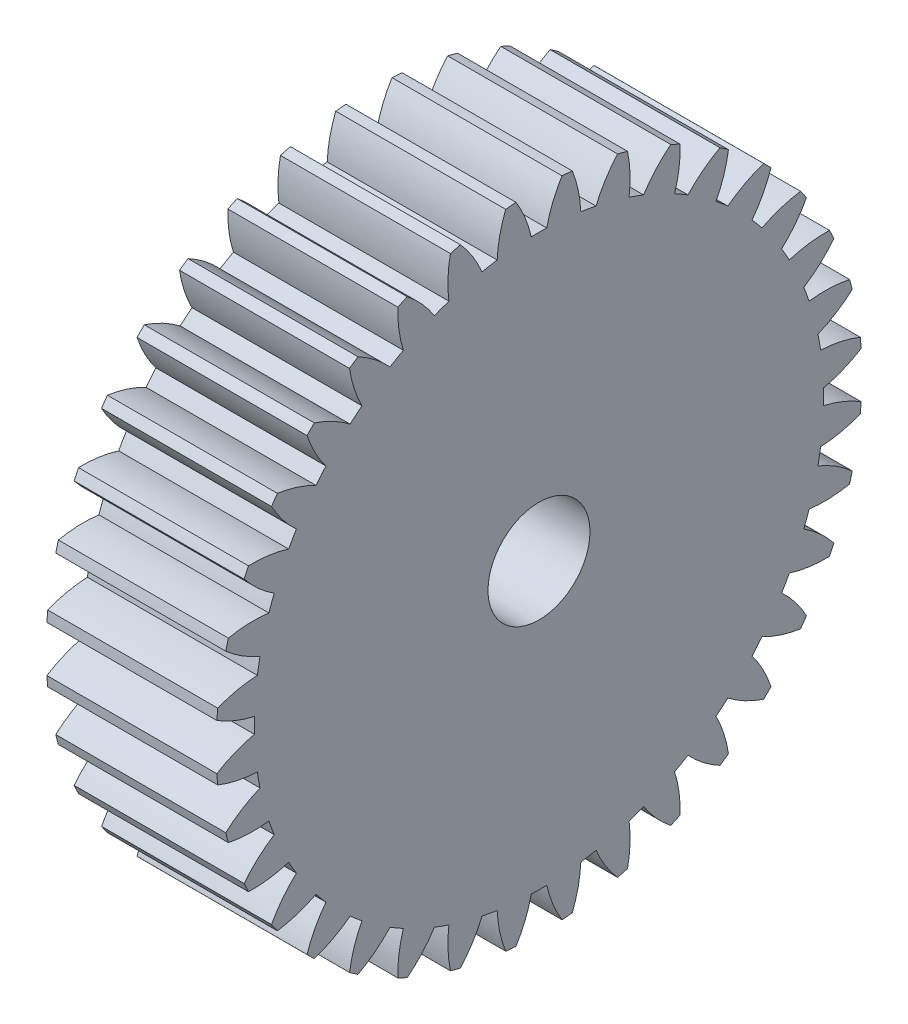
from build123d import *

# Parameters (mm, degrees)
BASPROSKE_W        = 10
BASPROSKE_H        = 19
TOOTHCUT_DEPTH     = 29.670542374
TEETHCUTS_COUNT    = 36
TEETHCUTS_ANGLE    = 350
BORSKE_R           = 2.5
BORE_DEPTH         = 50.0000508
SKETCH1_R          = 3
CUT_EXTRUDE1_DEPTH = 29.606546072


with BuildPart() as part:
    # BasProSke → Base-Revolve (revolve)
    with BuildSketch(Plane(origin=(0, 0, 0), x_dir=(1, 0, 0), z_dir=(0, 1, 0)), mode=Mode.PRIVATE) as base_revolve_sk:
        with Locations((5, 9.5)):
            Rectangle(BASPROSKE_W, BASPROSKE_H)
    revolve(base_revolve_sk.sketch.rotate(Axis((-10, 0, 0), (1, 0, 0)), 180), axis=Axis((-10, 0, 0), (1, 0, 0)))

    # TooCutSke → ToothCut (cut, through all)
    with BuildSketch(Plane(origin=(0, 0, 0), x_dir=(0, 0, -1), z_dir=(1, 0, 0))):
        with BuildLine():
            ThreePointArc((0.454664826, 16.742827745), (0, 16.749), (-0.454664826, 16.742827745))
            ThreePointArc((-0.454664826, 16.742827745), (-0.817558311, 17.898033097), (-1.368909141, 18.976088452))
            ThreePointArc((-1.368909141, 18.976088452), (0, 19.0254), (1.368909141, 18.976088452))
            ThreePointArc((1.368909141, 18.976088452), (0.817558311, 17.898033097), (0.454664826, 16.742827745))
        make_face()
    toothcut = extrude(amount=TOOTHCUT_DEPTH, mode=Mode.SUBTRACT)

    # TeethCuts: ToothCut ×36 about axis
    teethcuts_axis = Axis((-10, 0, 0), (1, 0, 0))
    for i in range(1, TEETHCUTS_COUNT):
        add(toothcut.rotate(teethcuts_axis, i * TEETHCUTS_ANGLE / (TEETHCUTS_COUNT - 1)), mode=Mode.SUBTRACT)

    # BorSke → Bore (cut, symmetric)
    with BuildSketch(Plane(origin=(0, 0, 0), x_dir=(0, 0, -1), z_dir=(1, 0, 0))):
        with Locations(Location((0, 0, 0), (0, 0, 180))):
            Circle(BORSKE_R)
    extrude(amount=BORE_DEPTH, both=True, mode=Mode.SUBTRACT)

    # Sketch1 → Cut-Extrude1 (cut, through all)
    with BuildSketch(Plane(origin=(10, 0, 0), x_dir=(0, 0, -1), z_dir=(1, 0, 0))):
        Circle(SKETCH1_R)
    extrude(amount=-CUT_EXTRUDE1_DEPTH, mode=Mode.SUBTRACT)


solid = part.part
